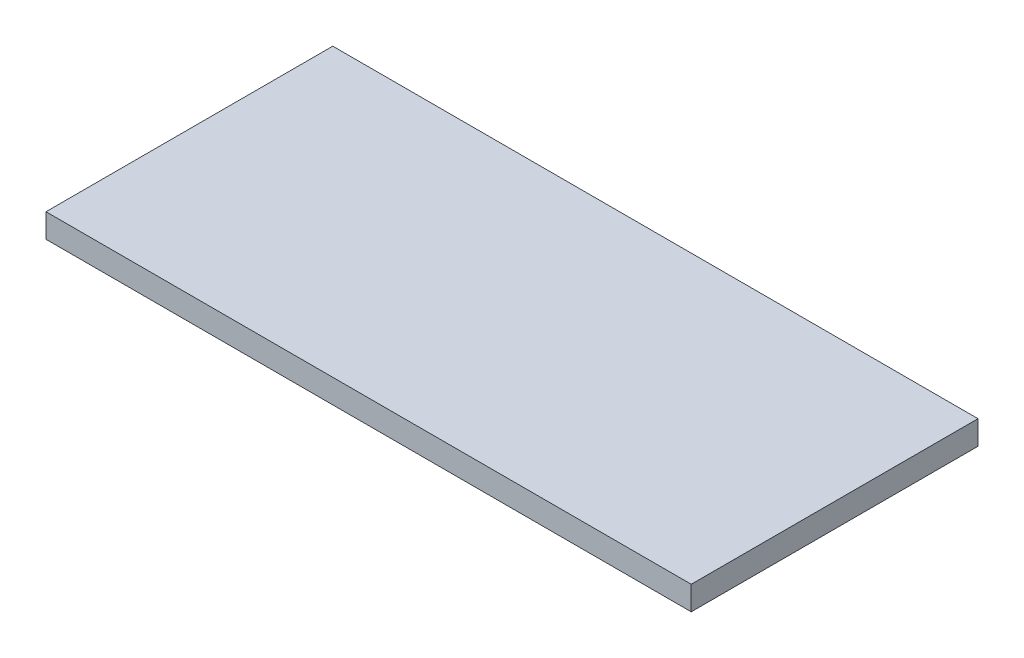
from build123d import *

# Parameters (mm, degrees)
SKETCH1_W           = 54
SKETCH1_H           = 24
BOSS_EXTRUDE1_DEPTH = 2


with BuildPart() as part:
    # Sketch1 → Boss-Extrude1 (new body)
    with BuildSketch(Plane(origin=(0, 0, 0), x_dir=(1, 0, 0), z_dir=(0, 1, 0))):
        Rectangle(SKETCH1_W, SKETCH1_H)
    extrude(amount=BOSS_EXTRUDE1_DEPTH)


solid = part.part
